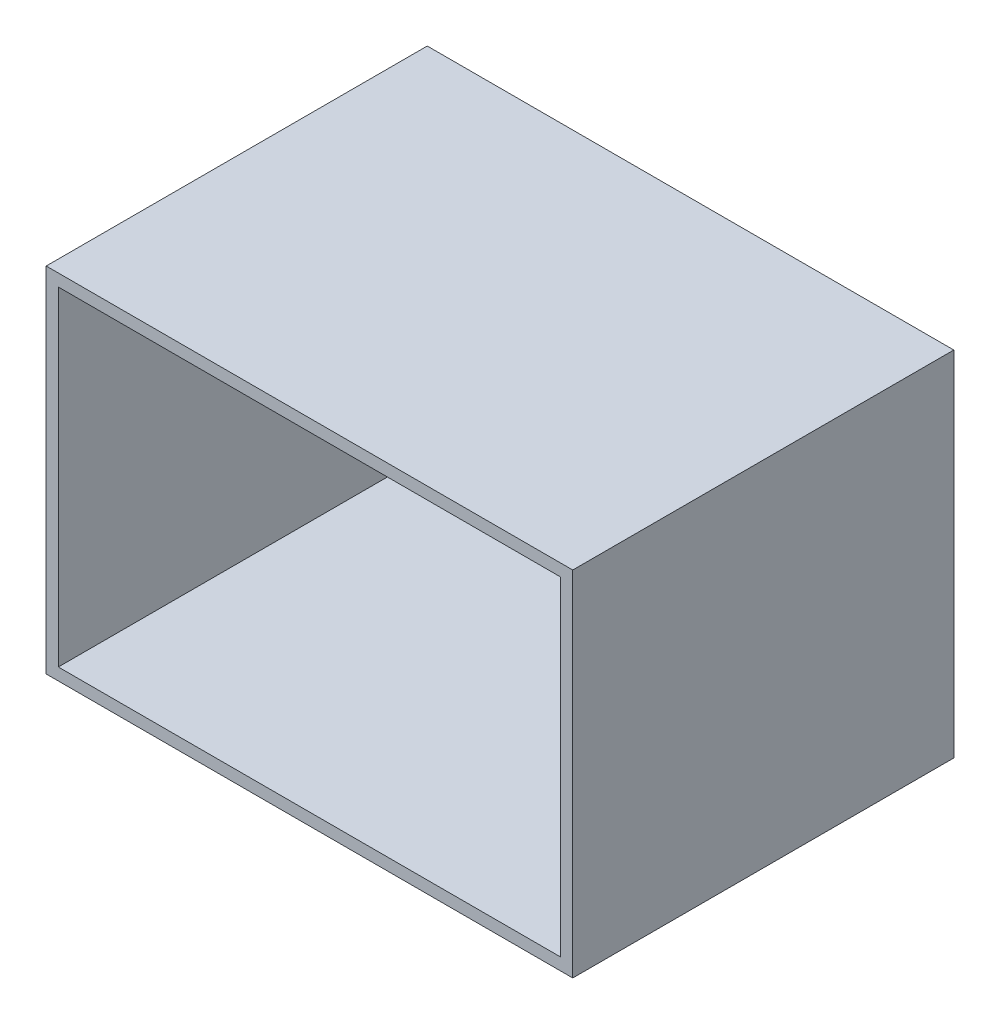
from build123d import *

# Parameters (mm, degrees)
SKETCH_1_W      = 76
SKETCH_1_H      = 51
SKETCH_1_W_2    = 72.5
SKETCH_1_H_2    = 47.5
EXTRUDE_1_DEPTH = 55


with BuildPart() as part:
    # ｽｹｯﾁ1 → ﾎﾞｽ - 押し出し1 (new body)
    with BuildSketch(Plane.XY):
        with Locations((2.643421505, -4.225352113)):
            Rectangle(SKETCH_1_W, SKETCH_1_H)
        with Locations((2.643421505, -4.225352113)):
            Rectangle(SKETCH_1_W_2, SKETCH_1_H_2, mode=Mode.SUBTRACT)
    extrude(amount=EXTRUDE_1_DEPTH)


solid = part.part
